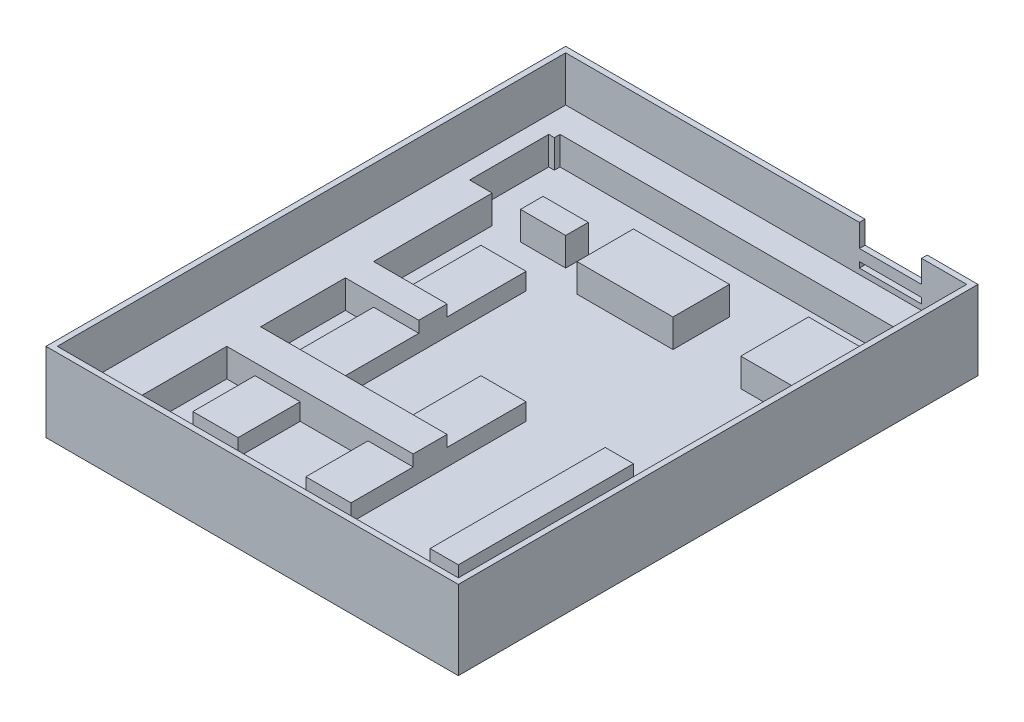
from build123d import *

# Parameters (mm, degrees)
SKETCH_8_W           = 73
SKETCH_8_H           = 92
EXTRUDE_5_DEPTH      = 12
SKETCH_9_W           = 71
SKETCH_9_H           = 90
CUT_EXTRUDE_3_DEPTH  = 10
SKETCH_11_W          = 73
SKETCH_11_H          = 6
EXTRUDE_8_DEPTH      = 7
SKETCH_12_W          = 4
SKETCH_12_H          = 19
EXTRUDE_10_DEPTH     = 7
SKETCH_13_W          = 4
SKETCH_13_H          = 21
EXTRUDE_13_DEPTH     = 7
SKETCH_14_W          = 7
SKETCH_14_H          = 12
EXTRUDE_14_DEPTH     = 7
SKETCH_15_W          = 7
SKETCH_15_H          = 58
EXTRUDE_15_DEPTH     = 7
SKETCH_17_W          = 40
SKETCH_17_H          = 6
EXTRUDE_16_DEPTH     = 7
SKETCH_18_W          = 20
SKETCH_18_H          = 5
EXTRUDE_17_DEPTH     = 7
SKETCH_19_W          = 16
SKETCH_19_H          = 4
EXTRUDE_18_DEPTH     = 7
SKETCH_20_W          = 4
SKETCH_20_H          = 7
EXTRUDE_19_DEPTH     = 7
SKETCH_21_W          = 5
SKETCH_21_H          = 31
EXTRUDE_22_DEPTH     = 5
SKETCH_23_W          = 9
SKETCH_23_H          = 12
EXTRUDE_23_DEPTH     = 7
SKETCH_24_W          = 17
SKETCH_24_H          = 10
EXTRUDE_24_DEPTH     = 7
SKETCH_25_W          = 8
SKETCH_25_H          = 4
EXTRUDE_25_DEPTH     = 7
SKETCH_28_W          = 8
SKETCH_28_H          = 31
EXTRUDE_26_DEPTH     = 5
SKETCH_32_W          = 10
SKETCH_32_H          = 1
CUT_EXTRUDE_4_DEPTH  = 5
SKETCH_33_W          = 8
SKETCH_33_H          = 51
EXTRUDE_27_DEPTH     = 5
SKETCH_35_W          = 10
SKETCH_35_H          = 1
EXTRUDE_28_DEPTH     = 10
SKETCH_37_W          = 11
SKETCH_37_H          = 1
CUT_EXTRUDE_7_DEPTH  = 1
SKETCH_39_W          = 11
SKETCH_39_H          = 1
CUT_EXTRUDE_8_DEPTH  = 1
SKETCH_40_W          = 1
SKETCH_40_H          = 1
EXTRUDE_29_DEPTH     = 7
SKETCH_41_R          = 1
CUT_EXTRUDE_9_DEPTH  = 9
EXTRUDE_30_DEPTH     = 4
SKETCH_44_W          = 4
SKETCH_44_H          = 6
SKETCH_44_W_2        = 3
SKETCH_44_H_2        = 5
SKETCH_44_H_3        = 7
SKETCH_44_W_3        = 7
SKETCH_44_H_4        = 7.504780259
EXTRUDE_31_DEPTH     = 7
SKETCH_45_W          = 73
SKETCH_45_H          = 1
CUT_EXTRUDE_10_DEPTH = 100
SKETCH_47_W          = 73
SKETCH_47_H          = 1
CUT_EXTRUDE_11_DEPTH = 100


with BuildPart() as part:
    # 草图8 → 凸台-拉伸5 (new body)
    with BuildSketch(Plane(origin=(0, 0, 0), x_dir=(1, 0, 0), z_dir=(0, 1, 0))):
        with Locations((36.5, 46)):
            Rectangle(SKETCH_8_W, SKETCH_8_H)
    extrude(amount=EXTRUDE_5_DEPTH)

    # 草图9 → 切除-拉伸3 (cut)
    with BuildSketch(Plane(origin=(0, 12, 0), x_dir=(1, 0, 0), z_dir=(0, 1, 0))):
        with Locations((36.5, 46)):
            Rectangle(SKETCH_9_W, SKETCH_9_H)
    extrude(amount=-CUT_EXTRUDE_3_DEPTH, mode=Mode.SUBTRACT)

    # 草图11 → 凸台-拉伸8 (add)
    with BuildSketch(Plane(origin=(0, 0, 0), x_dir=(1, 0, 0), z_dir=(0, 1, 0))):
        with Locations((36.5, 89)):
            Rectangle(SKETCH_11_W, SKETCH_11_H)
    extrude(amount=EXTRUDE_8_DEPTH)

    # 草图12 → 凸台-拉伸10 (add)
    with BuildSketch(Plane(origin=(0, 0, 0), x_dir=(1, 0, 0), z_dir=(0, 1, 0))):
        with Locations((71, 82.5)):
            Rectangle(SKETCH_12_W, SKETCH_12_H)
    extrude(amount=EXTRUDE_10_DEPTH)

    # 草图13 → 凸台-拉伸13 (add)
    with BuildSketch(Plane(origin=(0, 0, 0), x_dir=(1, 0, 0), z_dir=(0, 1, 0))):
        with Locations((2, 81.5)):
            Rectangle(SKETCH_13_W, SKETCH_13_H)
    extrude(amount=EXTRUDE_13_DEPTH)

    # 草图14 → 凸台-拉伸14 (add)
    with BuildSketch(Plane(origin=(0, 0, 0), x_dir=(1, 0, 0), z_dir=(0, 1, 0))):
        with Locations((4.5, 65)):
            Rectangle(SKETCH_14_W, SKETCH_14_H)
    extrude(amount=EXTRUDE_14_DEPTH)

    # 草图15 → 凸台-拉伸15 (add)
    with BuildSketch(Plane(origin=(0, 0, 0), x_dir=(1, 0, 0), z_dir=(0, 1, 0))):
        with Locations((4.5, 30)):
            Rectangle(SKETCH_15_W, SKETCH_15_H)
    extrude(amount=EXTRUDE_15_DEPTH)

    # 草图17 → 凸台-拉伸16 (add)
    with BuildSketch(Plane(origin=(0, 0, 0), x_dir=(1, 0, 0), z_dir=(0, 1, 0))):
        with Locations((21, 27)):
            Rectangle(SKETCH_17_W, SKETCH_17_H)
    extrude(amount=EXTRUDE_16_DEPTH)

    # 草图18 → 凸台-拉伸17 (add)
    with BuildSketch(Plane(origin=(0, 0, 0), x_dir=(1, 0, 0), z_dir=(0, 1, 0))):
        with Locations((11, 47.5)):
            Rectangle(SKETCH_18_W, SKETCH_18_H)
    extrude(amount=EXTRUDE_17_DEPTH)

    # 草图19 → 凸台-拉伸18 (add)
    with BuildSketch(Plane(origin=(0, 0, 0), x_dir=(1, 0, 0), z_dir=(0, 1, 0))):
        with Locations((64, 3)):
            Rectangle(SKETCH_19_W, SKETCH_19_H)
    extrude(amount=EXTRUDE_18_DEPTH)

    # 草图20 → 凸台-拉伸19 (add)
    with BuildSketch(Plane(origin=(0, 0, 0), x_dir=(1, 0, 0), z_dir=(0, 1, 0))):
        with Locations((70, 4.5)):
            Rectangle(SKETCH_20_W, SKETCH_20_H)
    extrude(amount=EXTRUDE_19_DEPTH)

    # 草图21 → 凸台-拉伸22 (add)
    with BuildSketch(Plane(origin=(0, 0, 0), x_dir=(1, 0, 0), z_dir=(0, 1, 0))):
        with Locations((57.5, 28.5)):
            Rectangle(SKETCH_21_W, SKETCH_21_H)
    extrude(amount=EXTRUDE_22_DEPTH)

    # 草图23 → 凸台-拉伸23 (add)
    with BuildSketch(Plane(origin=(0, 0, 0), x_dir=(1, 0, 0), z_dir=(0, 1, 0))):
        with Locations((59.5, 74)):
            Rectangle(SKETCH_23_W, SKETCH_23_H)
    extrude(amount=EXTRUDE_23_DEPTH)

    # 草图24 → 凸台-拉伸24 (add)
    with BuildSketch(Plane(origin=(0, 0, 0), x_dir=(1, 0, 0), z_dir=(0, 1, 0))):
        with Locations((34.5, 73)):
            Rectangle(SKETCH_24_W, SKETCH_24_H)
    extrude(amount=EXTRUDE_24_DEPTH)

    # 草图25 → 凸台-拉伸25 (add)
    with BuildSketch(Plane(origin=(0, 0, 0), x_dir=(1, 0, 0), z_dir=(0, 1, 0))):
        with Locations((17, 73)):
            Rectangle(SKETCH_25_W, SKETCH_25_H)
    extrude(amount=EXTRUDE_25_DEPTH)

    # 草图28 → 凸台-拉伸26 (add)
    with BuildSketch(Plane(origin=(0, 0, 0), x_dir=(1, 0, 0), z_dir=(0, 1, 0))):
        with Locations((37, 28.5)):
            Rectangle(SKETCH_28_W, SKETCH_28_H)
    extrude(amount=EXTRUDE_26_DEPTH)

    # 草图32 → 切除-拉伸4 (cut)
    with BuildSketch(Plane(origin=(0, 12, 0), x_dir=(1, 0, 0), z_dir=(0, 1, 0))):
        with Locations((58, 91.5)):
            Rectangle(SKETCH_32_W, SKETCH_32_H)
    extrude(amount=-CUT_EXTRUDE_4_DEPTH, mode=Mode.SUBTRACT)

    # 草图33 → 凸台-拉伸27 (add)
    with BuildSketch(Plane(origin=(0, 0, 0), x_dir=(1, 0, 0), z_dir=(0, 1, 0))):
        with Locations((17, 38.5)):
            Rectangle(SKETCH_33_W, SKETCH_33_H)
    extrude(amount=EXTRUDE_27_DEPTH)

    # 草图35 → 凸台-拉伸28 (add)
    with BuildSketch(Plane(origin=(0, 12, 0), x_dir=(1, 0, 0), z_dir=(0, 1, 0))):
        with Locations((58, 91.5)):
            Rectangle(SKETCH_35_W, SKETCH_35_H)
    extrude(amount=-EXTRUDE_28_DEPTH)

    # 草图37 → 切除-拉伸7 (cut)
    with BuildSketch(Plane(origin=(0, 12, 0), x_dir=(1, 0, 0), z_dir=(0, 1, 0))):
        with Locations((58.5, 91.5)):
            Rectangle(SKETCH_37_W, SKETCH_37_H)
    extrude(amount=-CUT_EXTRUDE_7_DEPTH, mode=Mode.SUBTRACT)

    # 草图39 → 切除-拉伸8 (cut)
    with BuildSketch(Plane(origin=(0, 8, 0), x_dir=(1, 0, 0), z_dir=(0, 1, 0))):
        with Locations((58.5, 91.5)):
            Rectangle(SKETCH_39_W, SKETCH_39_H)
    extrude(amount=CUT_EXTRUDE_8_DEPTH, mode=Mode.SUBTRACT)

    # 草图40 → 凸台-拉伸29 (add)
    with BuildSketch(Plane(origin=(0, 0, 0), x_dir=(1, 0, 0), z_dir=(0, 1, 0))):
        with Locations((4.5, 85.5)):
            Rectangle(SKETCH_40_W, SKETCH_40_H)
    extrude(amount=EXTRUDE_29_DEPTH)

    # 草图41 → 切除-拉伸9 (cut)
    with BuildSketch(Plane(origin=(0, 12, 0), x_dir=(1, 0, 0), z_dir=(0, 1, 0))):
        with Locations((4, 5)):
            Circle(SKETCH_41_R)
        with Locations((70, 6)):
            Circle(SKETCH_41_R)
        with Locations((70, 87)):
            Circle(SKETCH_41_R)
        with Locations((4, 87)):
            Circle(SKETCH_41_R)
    extrude(amount=-CUT_EXTRUDE_9_DEPTH, mode=Mode.SUBTRACT)

    # 草图42 → 凸台-拉伸30 (add)
    with BuildSketch(Plane(origin=(0, 12, 0), x_dir=(1, 0, 0), z_dir=(0, 1, 0))):
        Polygon((53, 92), (53, 91), (1, 91), (1, 1), (72, 1), (72, 91), (64, 91), (64, 92), (73, 92), (73, 0), (0, 0), (0, 92), align=None)
    extrude(amount=EXTRUDE_30_DEPTH)

    # 草图44 → 凸台-拉伸31 (add)
    with BuildSketch(Plane(origin=(0, 0, 0), x_dir=(1, 0, 0), z_dir=(0, 1, 0))):
        with Locations((3, 88)):
            Rectangle(SKETCH_44_W, SKETCH_44_H)
        with Locations((70.5, 88.5)):
            Rectangle(SKETCH_44_W_2, SKETCH_44_H_2)
        with Locations((70, 4.5)):
            Rectangle(SKETCH_44_W, SKETCH_44_H_3)
        with Locations((4.5, 4.75239013)):
            Rectangle(SKETCH_44_W_3, SKETCH_44_H_4)
    extrude(amount=EXTRUDE_31_DEPTH)

    # 草图45 → 切除-拉伸10 (cut)
    with BuildSketch(Plane.XY):
        with Locations((36.5, 0.5)):
            Rectangle(SKETCH_45_W, SKETCH_45_H)
    extrude(amount=-CUT_EXTRUDE_10_DEPTH, mode=Mode.SUBTRACT)

    # 草图47 → 切除-拉伸11 (cut)
    with BuildSketch(Plane.XY):
        with Locations((36.5, 15.5)):
            Rectangle(SKETCH_47_W, SKETCH_47_H)
    extrude(amount=-CUT_EXTRUDE_11_DEPTH, mode=Mode.SUBTRACT)


solid = part.part
